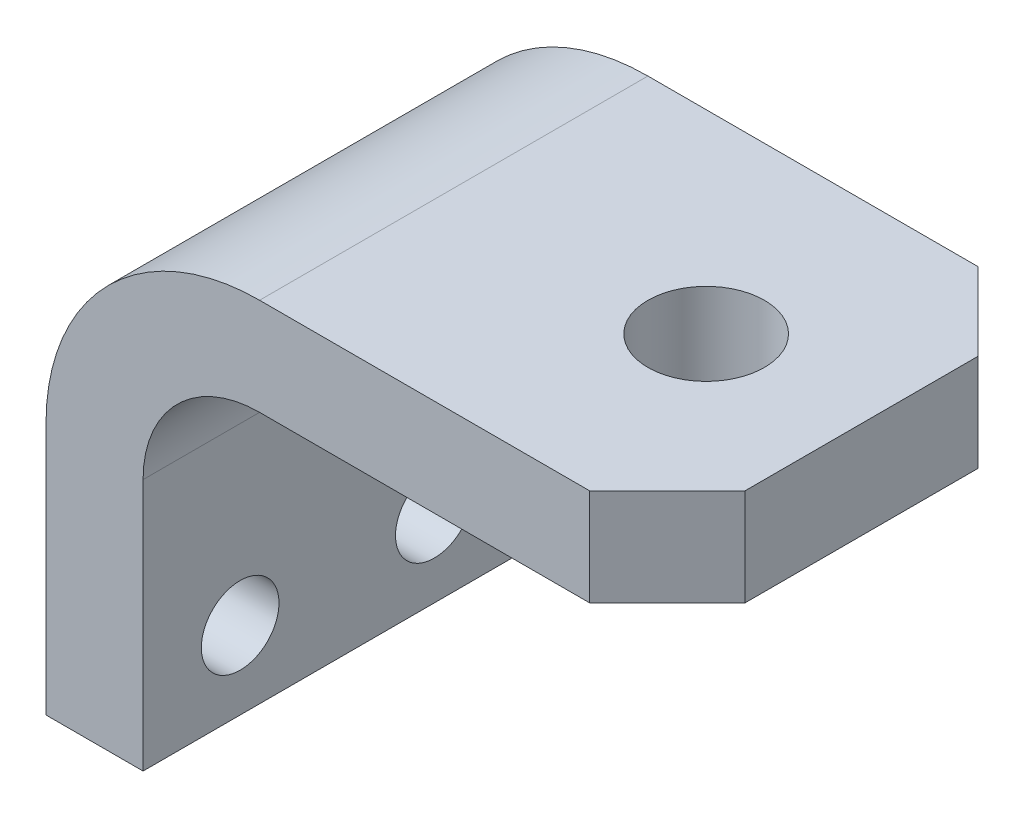
from build123d import *

# Parameters (mm, degrees)
BOSS_EXTRUDE1_DEPTH    = 31.75
SKETCH2_R              = 9.525
BALL_ANCHOR_HOLE_DEPTH = 77.2
F_45_DEG_CORNERS_DEPTH = 77.2
BOLT_HOLE_X_2_REACH    = 17.875
SKETCH4_R              = 6.35


with BuildPart() as part:
    # Sketch1 → Boss-Extrude1 (new body, symmetric)
    with BuildSketch(Plane.XY):
        with BuildLine():
            Line((-76.2, -60.325), (-76.2, -19.05))
            ThreePointArc((-76.2, -19.05), (-65.970704333, 5.645704333), (-41.275, 15.875))
            Line((-41.275, 15.875), (25.4, 15.875))
            Line((25.4, 15.875), (25.4, 0))
            Line((25.4, 0), (-41.275, 0))
            ThreePointArc((-41.275, 0), (-54.745384182, -5.579615818), (-60.325, -19.05))
            Line((-60.325, -19.05), (-60.325, -60.325))
            Line((-60.325, -60.325), (-76.2, -60.325))
        make_face()
    extrude(amount=BOSS_EXTRUDE1_DEPTH, both=True)

    # Sketch2 → Ball Anchor hole (cut, through all)
    with BuildSketch(Plane(origin=(0, 15.875, 0), x_dir=(1, 0, 0), z_dir=(0, 1, 0))):
        Circle(SKETCH2_R)
    extrude(amount=-BALL_ANCHOR_HOLE_DEPTH, mode=Mode.SUBTRACT)

    # Sketch3 → 45 Deg Corners (cut, through all)
    with BuildSketch(Plane(origin=(0, 15.875, 0), x_dir=(1, 0, 0), z_dir=(0, 1, 0))):
        Polygon((12.7, 31.75), (25.4, 19.05), (25.4, 31.75), align=None)
        Polygon((12.7, -31.75), (25.4, -19.05), (25.4, -31.75), align=None)
    extrude(amount=-F_45_DEG_CORNERS_DEPTH, mode=Mode.SUBTRACT)

    # Sketch4 → Bolt Hole x 2 (cut, up to next)
    with BuildSketch(Plane(origin=(-60.325, 0, 0), x_dir=(0, 0, -1), z_dir=(1, 0, 0)), mode=Mode.PRIVATE) as bolt_hole_x_2_sk1:
        with Locations((-15.875, -47.625)):
            Circle(SKETCH4_R)
    bolt_hole_x_2_tool1 = extrude(bolt_hole_x_2_sk1.sketch, amount=-BOLT_HOLE_X_2_REACH, mode=Mode.PRIVATE) & part.part
    add(bolt_hole_x_2_tool1.solids().sort_by_distance((-60.325, -47.625, 15.875))[0], mode=Mode.SUBTRACT)
    # Sketch4 → Bolt Hole x 2 (cut, up to next)
    with BuildSketch(Plane(origin=(-60.325, 0, 0), x_dir=(0, 0, -1), z_dir=(1, 0, 0)), mode=Mode.PRIVATE) as bolt_hole_x_2_sk2:
        with Locations((15.875, -47.625)):
            Circle(SKETCH4_R)
    bolt_hole_x_2_tool2 = extrude(bolt_hole_x_2_sk2.sketch, amount=-BOLT_HOLE_X_2_REACH, mode=Mode.PRIVATE) & part.part
    add(bolt_hole_x_2_tool2.solids().sort_by_distance((-60.325, -47.625, -15.875))[0], mode=Mode.SUBTRACT)


solid = part.part
